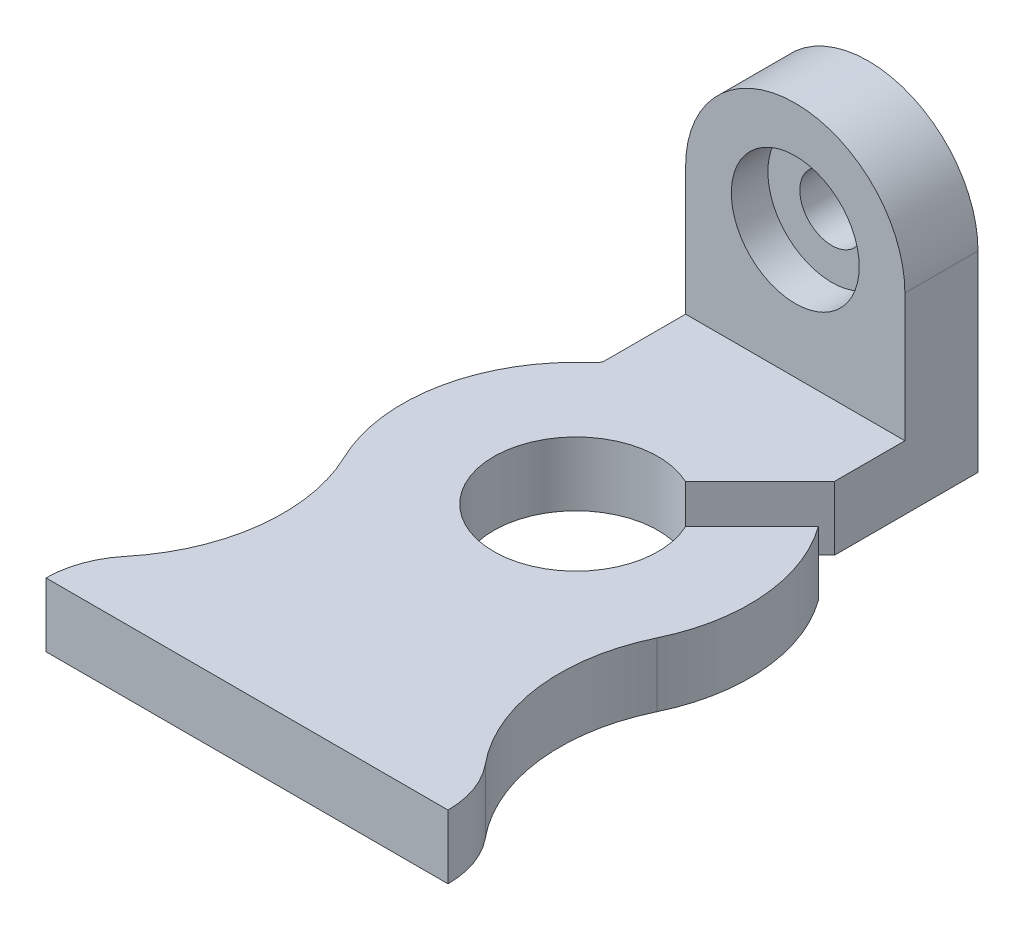
from build123d import *

# Parameters (mm, degrees)
SKETCH1_R           = 28.575
BOSS_EXTRUDE1_DEPTH = 22.225
SKETCH3_R           = 11.1125
BOSS_EXTRUDE2_DEPTH = 25.4
SKETCH4_R           = 22.225
CUT_EXTRUDE1_DEPTH  = 12.7
CUT_EXTRUDE2_DEPTH  = 23.225


with BuildPart() as part:
    # Sketch1 → Boss-Extrude1 (new body)
    with BuildSketch(Plane(origin=(0, 0, 0), x_dir=(1, 0, 0), z_dir=(0, 1, 0))):
        with BuildLine():
            Line((-69.85, 0), (69.85, 0))
            ThreePointArc((69.85, 0), (67.980720293, 10.733361765), (62.592988676, 20.202871225))
            ThreePointArc((62.592988676, 20.202871225), (48.540246687, 52.968596396), (54.358983449, 88.142657944))
            ThreePointArc((54.358983449, 88.142657944), (59.032707712, 126.719542875), (39.21125, 160.143031078))
            ThreePointArc((39.21125, 160.143031078), (38.391163038, 161.227624395), (38.1, 162.555822188))
            Line((38.1, 162.555822188), (38.1, 215.9))
            Line((38.1, 215.9), (-38.1, 215.9))
            Line((-38.1, 215.9), (-38.1, 162.555822188))
            ThreePointArc((-38.1, 162.555822188), (-38.391163038, 161.227624395), (-39.21125, 160.143031078))
            ThreePointArc((-39.21125, 160.143031078), (-59.032707712, 126.719542875), (-54.358983449, 88.142657944))
            ThreePointArc((-54.358983449, 88.142657944), (-48.540246687, 52.968596396), (-62.592988676, 20.202871225))
            ThreePointArc((-62.592988676, 20.202871225), (-67.980720293, 10.733361765), (-69.85, 0))
        make_face()
        with Locations((0, 114.3)):
            Circle(SKETCH1_R, mode=Mode.SUBTRACT)
    extrude(amount=BOSS_EXTRUDE1_DEPTH)

    # Sketch3 → Boss-Extrude2 (add)
    with BuildSketch(Plane(origin=(0, 0, -215.9), x_dir=(-1, 0, 0), z_dir=(0, 0, -1))):
        with BuildLine():
            Line((-38.1, 22.225), (38.1, 22.225))
            Line((38.1, 22.225), (38.1, 66.675))
            ThreePointArc((38.1, 66.675), (0, 104.775), (-38.1, 66.675))
            Line((-38.1, 66.675), (-38.1, 22.225))
        make_face()
        with Locations((0, 66.675)):
            Circle(SKETCH3_R, mode=Mode.SUBTRACT)
    extrude(amount=-BOSS_EXTRUDE2_DEPTH)

    # Sketch4 → Cut-Extrude1 (cut)
    with BuildSketch(Plane.XY.offset(-190.5)):
        with Locations((0, 66.675)):
            Circle(SKETCH4_R)
    extrude(amount=-CUT_EXTRUDE1_DEPTH, mode=Mode.SUBTRACT)

    # Sketch5 → Cut-Extrude2 (cut, through all)
    with BuildSketch(Plane(origin=(0, 22.225, 0), x_dir=(1, 0, 0), z_dir=(0, 1, 0))):
        with BuildLine():
            ThreePointArc((39.21125, 160.143031078), (40.964734437, 158.583136265), (42.656216575, 156.956216575))
            Line((42.656216575, 156.956216575), (51.593275336, 165.893275336))
            Line((51.593275336, 165.893275336), (44.768280684, 172.718269988))
            Line((44.768280684, 172.718269988), (38.1, 166.049989304))
            Line((38.1, 166.049989304), (38.1, 162.555822188))
            ThreePointArc((38.1, 162.555822188), (38.391163038, 161.227624395), (39.21125, 160.143031078))
        make_face()
        with BuildLine():
            ThreePointArc((12.193016824, 140.143006128), (16.442699368, 137.670243099), (20.205576272, 134.505576272))
            Line((20.205576272, 134.505576272), (42.656216575, 156.956216575))
            ThreePointArc((42.656216575, 156.956216575), (40.964734437, 158.583136265), (39.21125, 160.143031078))
            ThreePointArc((39.21125, 160.143031078), (38.391163038, 161.227624395), (38.1, 162.555822188))
            Line((38.1, 162.555822188), (38.1, 166.049989304))
            Line((38.1, 166.049989304), (12.193016824, 140.143006128))
        make_face()
        with BuildLine():
            Line((51.593275336, 165.893275336), (42.656216575, 156.956216575))
            ThreePointArc((42.656216575, 156.956216575), (45.942151261, 153.395068263), (48.931671801, 149.581682497))
            Line((48.931671801, 149.581682497), (58.418269988, 159.068280684))
            Line((58.418269988, 159.068280684), (51.593275336, 165.893275336))
        make_face()
        with BuildLine():
            Line((42.656216575, 156.956216575), (20.205576272, 134.505576272))
            ThreePointArc((20.205576272, 134.505576272), (23.370243099, 130.742699368), (25.843006128, 126.493016824))
            Line((25.843006128, 126.493016824), (48.931671801, 149.581682497))
            ThreePointArc((48.931671801, 149.581682497), (45.942151261, 153.395068263), (42.656216575, 156.956216575))
        make_face()
    extrude(amount=-CUT_EXTRUDE2_DEPTH, mode=Mode.SUBTRACT)


solid = part.part
